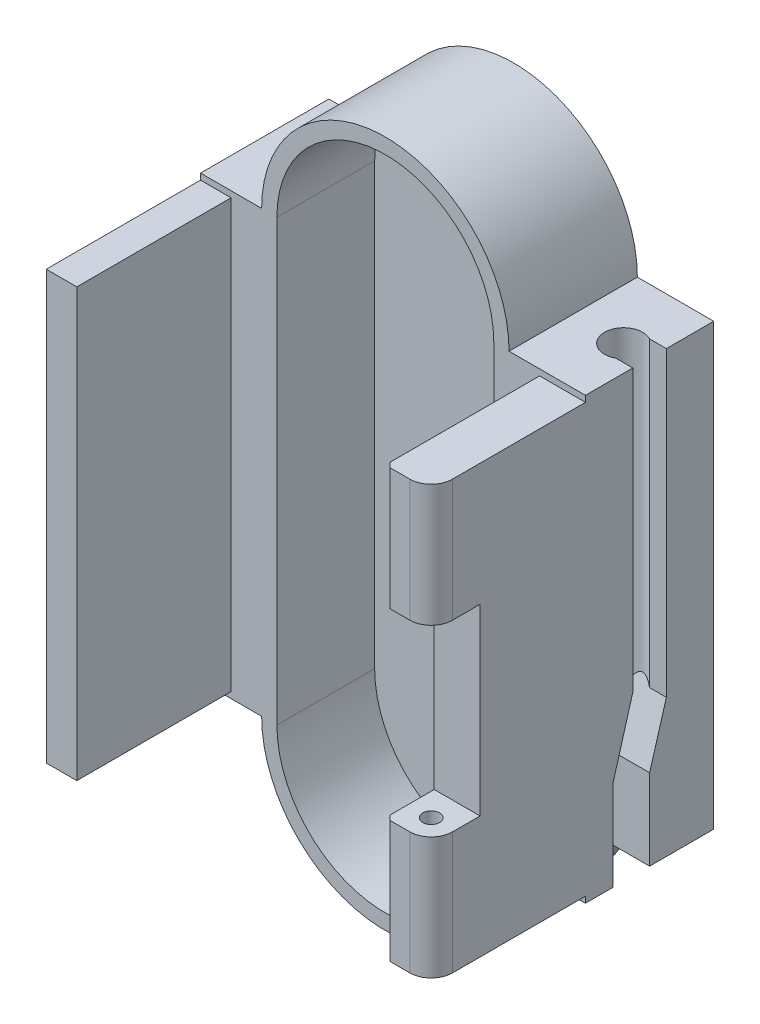
from build123d import *

# Parameters (mm, degrees)
SKETCH_1_W           = 24.2
SKETCH_1_H           = 45
EXTRUDE_1_DEPTH      = 18.5
CUT_EXTRUDE_1_DEPTH  = 10.1
CUT_EXTRUDE_2_DEPTH  = 6.4
CUT_EXTRUDE_3_DEPTH  = 9.4
CUT_EXTRUDE_4_DEPTH  = 9.4
SKETCH_6_W           = 2.4
SKETCH_6_H           = 2.4
CUT_EXTRUDE_5_DEPTH  = 6.4
SKETCH_8_W           = 3.4
SKETCH_8_H           = 2.4
CUT_EXTRUDE_7_DEPTH  = 2
SKETCH_9_W           = 2.5
SKETCH_9_H           = 2
CUT_EXTRUDE_8_DEPTH  = 0.4
SKETCH_12_W          = 18.5
SKETCH_12_H          = 26.4
EXTRUDE_2_DEPTH      = 1
SKETCH_13_R          = 1.25
CUT_EXTRUDE_10_DEPTH = 26.4
SKETCH_14_W          = 2.2
SKETCH_14_H          = 26.4
CUT_EXTRUDE_11_DEPTH = 1.5
CUT_EXTRUDE_13_DEPTH = 2.95
SKETCH_19_W          = 10.1
SKETCH_19_H          = 2
EXTRUDE_3_DEPTH      = 1
SKETCH_20_W          = 1.8
SKETCH_20_H          = 2.4
EXTRUDE_4_DEPTH      = 1
SKETCH_21_W          = 1
SKETCH_21_H          = 10.1
CUT_EXTRUDE_14_DEPTH = 0.4
SKETCH_22_W          = 4.2
SKETCH_22_H          = 2.4
EXTRUDE_5_DEPTH      = 1
EXTRUDE_6_DEPTH      = 2.95
SKETCH_25_W          = 3
SKETCH_25_H          = 12
CUT_EXTRUDE_15_DEPTH = 3.2
SKETCH_26_R          = 0.55
CUT_EXTRUDE_16_DEPTH = 26
FILLET_1_R           = 1.4
SKETCH_27_W          = 2
SKETCH_27_H          = 7
CUT_EXTRUDE_17_DEPTH = 1.2
CHAMFER_1_SIZE       = 0.3


with BuildPart() as part:
    # 草图1 → 凸台-拉伸1 (new body)
    with BuildSketch(Plane.XY):
        with Locations((12.1, -22.5)):
            Rectangle(SKETCH_1_W, SKETCH_1_H)
    extrude(amount=EXTRUDE_1_DEPTH)

    # 草图2 → 切除-拉伸1 (cut)
    with BuildSketch(Plane.XY.offset(18.5)):
        Polygon((0, 0), (0, -8.5), (2, -8.5), (2, -36.5), (0, -36.5), (0, -45), (24.2, -45), (24.2, -36.5), (22.2, -36.5), (22.2, -8.5), (24.2, -8.5), (24.2, 0), align=None)
    extrude(amount=-CUT_EXTRUDE_1_DEPTH, mode=Mode.SUBTRACT)

    # 草图3 → 切除-拉伸2 (cut)
    with BuildSketch(Plane.XY.offset(8.4)):
        with BuildLine():
            Line((5, -8.1), (5, -36.9))
            ThreePointArc((5, -36.9), (12.1, -44), (19.2, -36.9))
            Line((19.2, -36.9), (19.2, -8.1))
            ThreePointArc((19.2, -8.1), (12.1, -1), (5, -8.1))
        make_face()
    extrude(amount=-CUT_EXTRUDE_2_DEPTH, mode=Mode.SUBTRACT)

    # 草图4 → 切除-拉伸3 (cut, through all)
    with BuildSketch(Plane.XY.offset(8.4)):
        with BuildLine():
            Line((4, -8.1), (0, -8.1))
            Line((0, -8.1), (0, 0))
            Line((0, 0), (12.1, 0))
            ThreePointArc((12.1, 0), (6.372435072, -2.372435072), (4, -8.1))
        make_face()
        with BuildLine():
            Line((4, -36.9), (0, -36.9))
            Line((0, -36.9), (0, -45))
            Line((0, -45), (12.1, -45))
            ThreePointArc((12.1, -45), (6.372435072, -42.627564928), (4, -36.9))
        make_face()
    extrude(amount=-CUT_EXTRUDE_3_DEPTH, mode=Mode.SUBTRACT)

    # 草图5 → 切除-拉伸4 (cut, through all)
    with BuildSketch(Plane.XY.offset(8.4)):
        with BuildLine():
            Line((20.2, -36.9), (24.2, -36.9))
            Line((24.2, -36.9), (24.2, -45))
            Line((24.2, -45), (12.1, -45))
            ThreePointArc((12.1, -45), (17.827564928, -42.627564928), (20.2, -36.9))
        make_face()
        with BuildLine():
            Line((20.2, -8.1), (24.2, -8.1))
            Line((24.2, -8.1), (24.2, 0))
            Line((24.2, 0), (12.1, 0))
            ThreePointArc((12.1, 0), (17.827564928, -2.372435072), (20.2, -8.1))
        make_face()
    extrude(amount=-CUT_EXTRUDE_4_DEPTH, mode=Mode.SUBTRACT)

    # 草图6 → 切除-拉伸5 (cut)
    with BuildSketch(Plane(origin=(24.2, 0, 0), x_dir=(0, 0, -1), z_dir=(1, 0, 0))):
        with Locations((-5.4, -35.7)):
            Rectangle(SKETCH_6_W, SKETCH_6_H)
    extrude(amount=-CUT_EXTRUDE_5_DEPTH, mode=Mode.SUBTRACT)

    # 草图8 → 切除-拉伸7 (cut)
    with BuildSketch(Plane.XY.offset(8.4)):
        with Locations((20.9, -35.7)):
            Rectangle(SKETCH_8_W, SKETCH_8_H)
    extrude(amount=-CUT_EXTRUDE_7_DEPTH, mode=Mode.SUBTRACT)

    # 草图9 → 切除-拉伸8 (cut)
    with BuildSketch(Plane.ZY.offset(-22.2)):
        with Locations((9.65, -35.5)):
            Rectangle(SKETCH_9_W, SKETCH_9_H)
    extrude(amount=-CUT_EXTRUDE_8_DEPTH, mode=Mode.SUBTRACT)

    # 草图12 → 凸台-拉伸2 (add)
    with BuildSketch(Plane(origin=(24.2, 0, 0), x_dir=(0, 0, -1), z_dir=(1, 0, 0))):
        with Locations((-9.25, -21.3)):
            Rectangle(SKETCH_12_W, SKETCH_12_H)
    extrude(amount=EXTRUDE_2_DEPTH)

    # 草图13 → 切除-拉伸10 (cut)
    with BuildSketch(Plane(origin=(0, -8.1, 0), x_dir=(1, 0, 0), z_dir=(0, 1, 0))):
        with Locations((23.5, -4.2)):
            Circle(SKETCH_13_R)
    extrude(amount=-CUT_EXTRUDE_10_DEPTH, mode=Mode.SUBTRACT)

    # 草图14 → 切除-拉伸11 (cut)
    with BuildSketch(Plane(origin=(25.2, 0, 0), x_dir=(0, 0, -1), z_dir=(1, 0, 0))):
        with Locations((-4.2, -21.3)):
            Rectangle(SKETCH_14_W, SKETCH_14_H)
    extrude(amount=-CUT_EXTRUDE_11_DEPTH, mode=Mode.SUBTRACT)

    # 草图17 → 切除-拉伸13 (cut)
    with BuildSketch(Plane(origin=(25.2, 0, 0), x_dir=(0, 0, -1), z_dir=(1, 0, 0))):
        Polygon((-6.6, -34.5), (-6.6, -31), (-5.3, -26.5), (-4.2, -26.5), (-4.2, -34.5), align=None)
    extrude(amount=-CUT_EXTRUDE_13_DEPTH, mode=Mode.SUBTRACT)

    # 草图19 → 凸台-拉伸3 (add)
    with BuildSketch(Plane(origin=(24.2, 0, 0), x_dir=(0, 0, -1), z_dir=(1, 0, 0))):
        with Locations((-13.45, -35.5)):
            Rectangle(SKETCH_19_W, SKETCH_19_H)
    extrude(amount=EXTRUDE_3_DEPTH)

    # 草图20 → 凸台-拉伸4 (add)
    with BuildSketch(Plane(origin=(24.2, 0, 0), x_dir=(0, 0, -1), z_dir=(1, 0, 0))):
        with Locations((-7.5, -35.7)):
            Rectangle(SKETCH_20_W, SKETCH_20_H)
    extrude(amount=EXTRUDE_4_DEPTH)

    # 草图21 → 切除-拉伸14 (cut)
    with BuildSketch(Plane(origin=(0, -8.1, 0), x_dir=(1, 0, 0), z_dir=(0, 1, 0))):
        with Locations((24.7, -13.45)):
            Rectangle(SKETCH_21_W, SKETCH_21_H)
    extrude(amount=-CUT_EXTRUDE_14_DEPTH, mode=Mode.SUBTRACT)

    # 草图22 → 凸台-拉伸5 (add)
    with BuildSketch(Plane(origin=(24.2, 0, 0), x_dir=(0, 0, -1), z_dir=(1, 0, 0))):
        with Locations((-2.1, -35.7)):
            Rectangle(SKETCH_22_W, SKETCH_22_H)
    extrude(amount=EXTRUDE_5_DEPTH)

    # 草图23 → 凸台-拉伸6 (add)
    with BuildSketch(Plane(origin=(22.25, 0, 0), x_dir=(0, 0, -1), z_dir=(1, 0, 0))):
        Polygon((-4.2, -34.5), (-2.4, -34.5), (-2.4, -25.5), (-4.2, -31.6), align=None)
    extrude(amount=EXTRUDE_6_DEPTH)

    # 草图25 → 切除-拉伸15 (cut)
    with BuildSketch(Plane.XY.offset(18.5)):
        with Locations((23.7, -22.5)):
            Rectangle(SKETCH_25_W, SKETCH_25_H)
    extrude(amount=-CUT_EXTRUDE_15_DEPTH, mode=Mode.SUBTRACT)

    # 草图26 → 切除-拉伸16 (cut)
    with BuildSketch(Plane.XZ.offset(36.5)):
        with Locations((23.7, 17)):
            Circle(SKETCH_26_R)
    extrude(amount=-CUT_EXTRUDE_16_DEPTH, mode=Mode.SUBTRACT)

    # 圆角1
    fillet_1_edges = [part.edges().sort_by_distance(p)[0] for p in [
        (25.2, -12.5, 18.5),
        (25.2, -32.5, 18.5),
    ]]
    fillet(fillet_1_edges, radius=FILLET_1_R)

    # 草图27 → 切除-拉伸17 (cut)
    with BuildSketch(Plane.ZY):
        with Locations((16, -14)):
            Rectangle(SKETCH_27_W, SKETCH_27_H)
        with Locations((16, -31)):
            Rectangle(SKETCH_27_W, SKETCH_27_H)
    extrude(amount=-CUT_EXTRUDE_17_DEPTH, mode=Mode.SUBTRACT)

    # 倒角1
    chamfer_1_edges = [part.edges().sort_by_distance(p)[0] for p in [
        (22.2, -32.5, 18.5),
        (22.2, -12.5, 18.5),
    ]]
    chamfer(chamfer_1_edges, length=CHAMFER_1_SIZE)


solid = part.part
